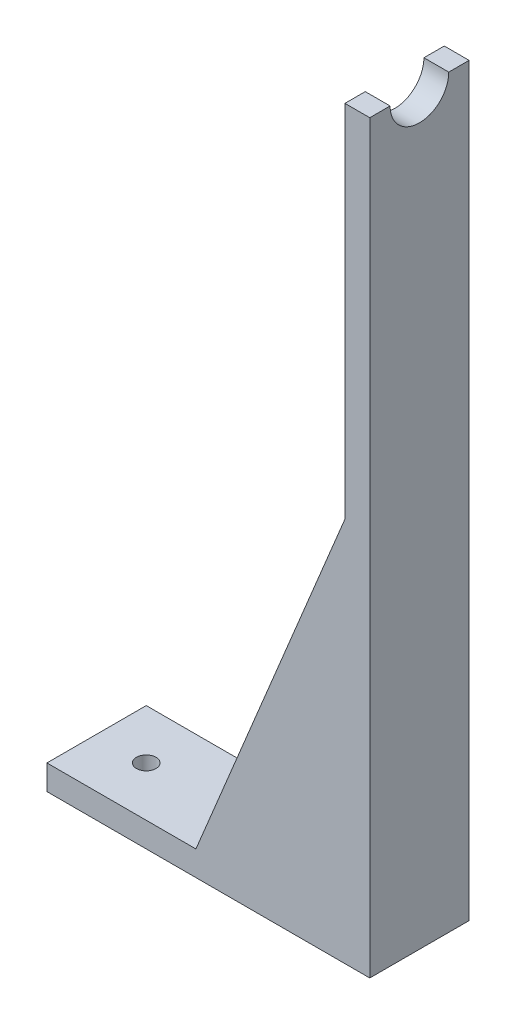
from build123d import *

# Parameters (mm, degrees)
SKETCH2_W           = 76.2
SKETCH2_H           = 25.4
SKETCH2_R           = 2.5
BOSS_EXTRUDE1_DEPTH = 6.35
SKETCH3_W           = 25.4
SKETCH3_H           = 190.5
BOSS_EXTRUDE2_DEPTH = 6.35
BOSS_EXTRUDE3_DEPTH = 5.08
SKETCH5_R           = 7.5
CUT_EXTRUDE1_DEPTH  = 37.592


with BuildPart() as part:
    # Sketch2 → Boss-Extrude1 (new body)
    with BuildSketch(Plane(origin=(0, 0, 0), x_dir=(1, 0, 0), z_dir=(0, 1, 0))):
        Rectangle(SKETCH2_W, SKETCH2_H)
        with Locations((-25.4, 0)):
            Circle(SKETCH2_R, mode=Mode.SUBTRACT)
        with Locations((25.4, 0)):
            Circle(SKETCH2_R, mode=Mode.SUBTRACT)
    extrude(amount=BOSS_EXTRUDE1_DEPTH)

    # Sketch3 → Boss-Extrude2 (add)
    with BuildSketch(Plane(origin=(38.1, 0, 0), x_dir=(0, 0, -1), z_dir=(1, 0, 0))):
        with Locations((0, 95.25)):
            Rectangle(SKETCH3_W, SKETCH3_H)
    extrude(amount=BOSS_EXTRUDE2_DEPTH)


with BuildPart() as body_2:
    # Sketch4 → Boss-Extrude3 (new body)
    with BuildSketch(Plane.XY.offset(12.7)):
        Polygon((22.9, 6.35), (27.9, 6.35), (38.1, 6.35), (38.1, 98.425), (0, 6.35), align=None)
    extrude(amount=-BOSS_EXTRUDE3_DEPTH)


with BuildPart() as body_3:
    # Mirror2: mirrored copy
    add(body_2.part.mirror(Plane.XY))


with BuildPart() as body_2_1:
    add(body_2.part)

    # Combine1: union body 3, part
    add(body_3.part)
    add(part.part)

    # Sketch5 → Cut-Extrude1 (cut)
    with BuildSketch(Plane(origin=(44.45, 0, 0), x_dir=(0, 0, -1), z_dir=(1, 0, 0))):
        with Locations((0, 190.5)):
            Circle(SKETCH5_R)
    extrude(amount=-CUT_EXTRUDE1_DEPTH, mode=Mode.SUBTRACT)


solid = body_2_1.part
